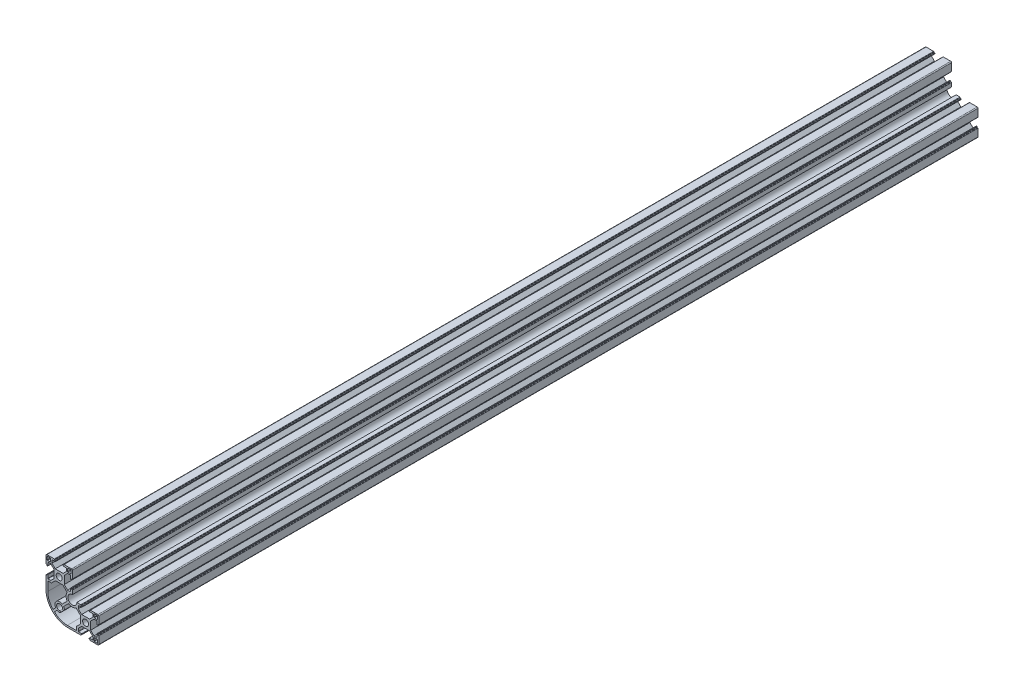
from build123d import *

# Parameters (mm, degrees)
SKETCH_1_R      = 3.4
EXTRUDE_1_DEPTH = 1000


with BuildPart() as part:
    # Эскиз1 → Бобышка-Вытянуть1 (new body)
    with BuildSketch(Plane.XY):
        with BuildLine():
            Line((-15, 38.25), (-15, 44))
            ThreePointArc((-15, 44), (-14.707106781, 44.707106781), (-14, 45))
            Line((-14, 45), (-8.25, 45))
            Line((-8.25, 45), (-5.5, 45))
            ThreePointArc((-5.5, 45), (-5.287867966, 44.912132034), (-5.2, 44.7))
            Line((-5.2, 44.7), (-5.2, 44.3))
            ThreePointArc((-5.2, 44.3), (-5.112132034, 44.087867966), (-4.9, 44))
            Line((-4.9, 44), (-4.4, 44))
            ThreePointArc((-4.4, 44), (-4.187867966, 43.912132034), (-4.1, 43.7))
            Line((-4.1, 43.7), (-4.1, 43.3))
            ThreePointArc((-4.1, 43.3), (-4.187867966, 43.087867966), (-4.4, 43))
            Line((-4.4, 43), (-7.95, 43))
            ThreePointArc((-7.95, 43), (-8.162132034, 42.912132034), (-8.25, 42.7))
            Line((-8.25, 42.7), (-8.25, 39.55))
            Line((-8.25, 39.55), (-4.5, 35.8))
            Line((-4.5, 35.8), (4.5, 35.8))
            Line((4.5, 35.8), (8.25, 39.55))
            Line((8.25, 39.55), (8.25, 42.7))
            ThreePointArc((8.25, 42.7), (8.162132034, 42.912132034), (7.95, 43))
            Line((7.95, 43), (4.4, 43))
            ThreePointArc((4.4, 43), (4.187867966, 43.087867966), (4.1, 43.3))
            Line((4.1, 43.3), (4.1, 43.7))
            ThreePointArc((4.1, 43.7), (4.187867966, 43.912132034), (4.4, 44))
            Line((4.4, 44), (4.9, 44))
            ThreePointArc((4.9, 44), (5.112132034, 44.087867966), (5.2, 44.3))
            Line((5.2, 44.3), (5.2, 44.7))
            ThreePointArc((5.2, 44.7), (5.287867966, 44.912132034), (5.5, 45))
            Line((5.5, 45), (8.25, 45))
            Line((8.25, 45), (14, 45))
            ThreePointArc((14, 45), (14.707106781, 44.707106781), (15, 44))
            Line((15, 44), (15, 38.25))
            Line((15, 38.25), (15, 35.5))
            ThreePointArc((15, 35.5), (14.912132034, 35.287867966), (14.7, 35.2))
            Line((14.7, 35.2), (14.3, 35.2))
            ThreePointArc((14.3, 35.2), (14.087867966, 35.112132034), (14, 34.9))
            Line((14, 34.9), (14, 34.4))
            ThreePointArc((14, 34.4), (13.912132034, 34.187867966), (13.7, 34.1))
            Line((13.7, 34.1), (13.3, 34.1))
            ThreePointArc((13.3, 34.1), (13.087867966, 34.187867966), (13, 34.4))
            Line((13, 34.4), (13, 37.95))
            ThreePointArc((13, 37.95), (12.912132034, 38.162132034), (12.7, 38.25))
            Line((12.7, 38.25), (9.55, 38.25))
            Line((9.55, 38.25), (5.8, 34.5))
            Line((5.8, 34.5), (5.8, 25.5))
            Line((5.8, 25.5), (9.55, 21.75))
            Line((9.55, 21.75), (12.7, 21.75))
            ThreePointArc((12.7, 21.75), (12.912132034, 21.837867966), (13, 22.05))
            Line((13, 22.05), (13, 25.6))
            ThreePointArc((13, 25.6), (13.087867966, 25.812132034), (13.3, 25.9))
            Line((13.3, 25.9), (13.7, 25.9))
            ThreePointArc((13.7, 25.9), (13.912132034, 25.812132034), (14, 25.6))
            Line((14, 25.6), (14, 25.1))
            ThreePointArc((14, 25.1), (14.087867966, 24.887867966), (14.3, 24.8))
            Line((14.3, 24.8), (14.7, 24.8))
            ThreePointArc((14.7, 24.8), (14.912132034, 24.712132034), (15, 24.5))
            Line((15, 24.5), (15, 21.75))
            Line((15, 21.75), (15, 20.1))
            ThreePointArc((15, 20.1), (11.393755416, 11.393755416), (20.1, 15))
            Line((20.1, 15), (21.75, 15))
            Line((21.75, 15), (24.5, 15))
            ThreePointArc((24.5, 15), (24.712132034, 14.912132034), (24.8, 14.7))
            Line((24.8, 14.7), (24.8, 14.3))
            ThreePointArc((24.8, 14.3), (24.887867966, 14.087867966), (25.1, 14))
            Line((25.1, 14), (25.6, 14))
            ThreePointArc((25.6, 14), (25.812132034, 13.912132034), (25.9, 13.7))
            Line((25.9, 13.7), (25.9, 13.3))
            ThreePointArc((25.9, 13.3), (25.812132034, 13.087867966), (25.6, 13))
            Line((25.6, 13), (22.05, 13))
            ThreePointArc((22.05, 13), (21.837867966, 12.912132034), (21.75, 12.7))
            Line((21.75, 12.7), (21.75, 9.55))
            Line((21.75, 9.55), (25.5, 5.8))
            Line((25.5, 5.8), (34.5, 5.8))
            Line((34.5, 5.8), (38.25, 9.55))
            Line((38.25, 9.55), (38.25, 12.7))
            ThreePointArc((38.25, 12.7), (38.162132034, 12.912132034), (37.95, 13))
            Line((37.95, 13), (34.4, 13))
            ThreePointArc((34.4, 13), (34.187867966, 13.087867966), (34.1, 13.3))
            Line((34.1, 13.3), (34.1, 13.7))
            ThreePointArc((34.1, 13.7), (34.187867966, 13.912132034), (34.4, 14))
            Line((34.4, 14), (34.9, 14))
            ThreePointArc((34.9, 14), (35.112132034, 14.087867966), (35.2, 14.3))
            Line((35.2, 14.3), (35.2, 14.7))
            ThreePointArc((35.2, 14.7), (35.287867966, 14.912132034), (35.5, 15))
            Line((35.5, 15), (38.25, 15))
            Line((38.25, 15), (44, 15))
            ThreePointArc((44, 15), (44.707106781, 14.707106781), (45, 14))
            Line((45, 14), (45, 8.25))
            Line((45, 8.25), (45, 5.5))
            ThreePointArc((45, 5.5), (44.912132034, 5.287867966), (44.7, 5.2))
            Line((44.7, 5.2), (44.3, 5.2))
            ThreePointArc((44.3, 5.2), (44.087867966, 5.112132034), (44, 4.9))
            Line((44, 4.9), (44, 4.4))
            ThreePointArc((44, 4.4), (43.912132034, 4.187867966), (43.7, 4.1))
            Line((43.7, 4.1), (43.3, 4.1))
            ThreePointArc((43.3, 4.1), (43.087867966, 4.187867966), (43, 4.4))
            Line((43, 4.4), (43, 7.95))
            ThreePointArc((43, 7.95), (42.912132034, 8.162132034), (42.7, 8.25))
            Line((42.7, 8.25), (39.55, 8.25))
            Line((39.55, 8.25), (35.8, 4.5))
            Line((35.8, 4.5), (35.8, -4.5))
            Line((35.8, -4.5), (39.55, -8.25))
            Line((39.55, -8.25), (42.7, -8.25))
            ThreePointArc((42.7, -8.25), (42.912132034, -8.162132034), (43, -7.95))
            Line((43, -7.95), (43, -4.4))
            ThreePointArc((43, -4.4), (43.087867966, -4.187867966), (43.3, -4.1))
            Line((43.3, -4.1), (43.7, -4.1))
            ThreePointArc((43.7, -4.1), (43.912132034, -4.187867966), (44, -4.4))
            Line((44, -4.4), (44, -4.9))
            ThreePointArc((44, -4.9), (44.087867966, -5.112132034), (44.3, -5.2))
            Line((44.3, -5.2), (44.7, -5.2))
            ThreePointArc((44.7, -5.2), (44.912132034, -5.287867966), (45, -5.5))
            Line((45, -5.5), (45, -8.25))
            Line((45, -8.25), (45, -14))
            ThreePointArc((45, -14), (44.707106781, -14.707106781), (44, -15))
            Line((44, -15), (38.25, -15))
            Line((38.25, -15), (35.5, -15))
            ThreePointArc((35.5, -15), (35.287867966, -14.912132034), (35.2, -14.7))
            Line((35.2, -14.7), (35.2, -14.3))
            ThreePointArc((35.2, -14.3), (35.112132034, -14.087867966), (34.9, -14))
            Line((34.9, -14), (34.4, -14))
            ThreePointArc((34.4, -14), (34.187867966, -13.912132034), (34.1, -13.7))
            Line((34.1, -13.7), (34.1, -13.3))
            ThreePointArc((34.1, -13.3), (34.187867966, -13.087867966), (34.4, -13))
            Line((34.4, -13), (37.95, -13))
            ThreePointArc((37.95, -13), (38.162132034, -12.912132034), (38.25, -12.7))
            Line((38.25, -12.7), (38.25, -9.55))
            Line((38.25, -9.55), (34.5, -5.8))
            Line((34.5, -5.8), (25.5, -5.8))
            Line((25.5, -5.8), (21.75, -9.55))
            Line((21.75, -9.55), (21.75, -12.7))
            ThreePointArc((21.75, -12.7), (21.837867966, -12.912132034), (22.05, -13))
            Line((22.05, -13), (25.6, -13))
            ThreePointArc((25.6, -13), (25.812132034, -13.087867966), (25.9, -13.3))
            Line((25.9, -13.3), (25.9, -13.7))
            ThreePointArc((25.9, -13.7), (25.812132034, -13.912132034), (25.6, -14))
            Line((25.6, -14), (25.1, -14))
            ThreePointArc((25.1, -14), (24.887867966, -14.087867966), (24.8, -14.3))
            Line((24.8, -14.3), (24.8, -14.7))
            ThreePointArc((24.8, -14.7), (24.712132034, -14.912132034), (24.5, -15))
            Line((24.5, -15), (21.75, -15))
            Line((21.75, -15), (10, -15))
            ThreePointArc((10, -15), (-7.67766953, -7.67766953), (-15, 10))
            Line((-15, 10), (-15, 21.75))
            Line((-15, 21.75), (-15, 24.5))
            ThreePointArc((-15, 24.5), (-14.912132034, 24.712132034), (-14.7, 24.8))
            Line((-14.7, 24.8), (-14.3, 24.8))
            ThreePointArc((-14.3, 24.8), (-14.087867966, 24.887867966), (-14, 25.1))
            Line((-14, 25.1), (-14, 25.6))
            ThreePointArc((-14, 25.6), (-13.912132034, 25.812132034), (-13.7, 25.9))
            Line((-13.7, 25.9), (-13.3, 25.9))
            ThreePointArc((-13.3, 25.9), (-13.087867966, 25.812132034), (-13, 25.6))
            Line((-13, 25.6), (-13, 22.05))
            ThreePointArc((-13, 22.05), (-12.912132034, 21.837867966), (-12.7, 21.75))
            Line((-12.7, 21.75), (-9.55, 21.75))
            Line((-9.55, 21.75), (-5.8, 25.5))
            Line((-5.8, 25.5), (-5.8, 34.5))
            Line((-5.8, 34.5), (-9.55, 38.25))
            Line((-9.55, 38.25), (-12.7, 38.25))
            ThreePointArc((-12.7, 38.25), (-12.912132034, 38.162132034), (-13, 37.95))
            Line((-13, 37.95), (-13, 34.4))
            ThreePointArc((-13, 34.4), (-13.087867966, 34.187867966), (-13.3, 34.1))
            Line((-13.3, 34.1), (-13.7, 34.1))
            ThreePointArc((-13.7, 34.1), (-13.912132034, 34.187867966), (-14, 34.4))
            Line((-14, 34.4), (-14, 34.9))
            ThreePointArc((-14, 34.9), (-14.087867966, 35.112132034), (-14.3, 35.2))
            Line((-14.3, 35.2), (-14.7, 35.2))
            ThreePointArc((-14.7, 35.2), (-14.912132034, 35.287867966), (-15, 35.5))
            Line((-15, 35.5), (-15, 38.25))
        make_face()
        with Locations((0, 30)):
            Circle(SKETCH_1_R, mode=Mode.SUBTRACT)
        with Locations((30, 0)):
            Circle(SKETCH_1_R, mode=Mode.SUBTRACT)
        with BuildLine():
            Line((-13.2, 43.7), (-10.2, 43.7))
            ThreePointArc((-10.2, 43.7), (-9.846446609, 43.553553391), (-9.7, 43.2))
            Line((-9.7, 43.2), (-9.7, 40.2))
            ThreePointArc((-9.7, 40.2), (-9.846446609, 39.846446609), (-10.2, 39.7))
            Line((-10.2, 39.7), (-13.2, 39.7))
            ThreePointArc((-13.2, 39.7), (-13.553553391, 39.846446609), (-13.7, 40.2))
            Line((-13.7, 40.2), (-13.7, 43.2))
            ThreePointArc((-13.7, 43.2), (-13.553553391, 43.553553391), (-13.2, 43.7))
        make_face(mode=Mode.SUBTRACT)
        with BuildLine():
            Line((13.2, 43.7), (10.2, 43.7))
            ThreePointArc((10.2, 43.7), (9.846446609, 43.553553391), (9.7, 43.2))
            Line((9.7, 43.2), (9.7, 40.2))
            ThreePointArc((9.7, 40.2), (9.846446609, 39.846446609), (10.2, 39.7))
            Line((10.2, 39.7), (13.2, 39.7))
            ThreePointArc((13.2, 39.7), (13.553553391, 39.846446609), (13.7, 40.2))
            Line((13.7, 40.2), (13.7, 43.2))
            ThreePointArc((13.7, 43.2), (13.553553391, 43.553553391), (13.2, 43.7))
        make_face(mode=Mode.SUBTRACT)
        with BuildLine():
            Line((43.7, 13.2), (43.7, 10.2))
            ThreePointArc((43.7, 10.2), (43.553553391, 9.846446609), (43.2, 9.7))
            Line((43.2, 9.7), (40.2, 9.7))
            ThreePointArc((40.2, 9.7), (39.846446609, 9.846446609), (39.7, 10.2))
            Line((39.7, 10.2), (39.7, 13.2))
            ThreePointArc((39.7, 13.2), (39.846446609, 13.553553391), (40.2, 13.7))
            Line((40.2, 13.7), (43.2, 13.7))
            ThreePointArc((43.2, 13.7), (43.553553391, 13.553553391), (43.7, 13.2))
        make_face(mode=Mode.SUBTRACT)
        with BuildLine():
            Line((39.7, -13.2), (39.7, -10.2))
            ThreePointArc((39.7, -10.2), (39.846446609, -9.846446609), (40.2, -9.7))
            Line((40.2, -9.7), (43.2, -9.7))
            ThreePointArc((43.2, -9.7), (43.553553391, -9.846446609), (43.7, -10.2))
            Line((43.7, -10.2), (43.7, -13.2))
            ThreePointArc((43.7, -13.2), (43.553553391, -13.553553391), (43.2, -13.7))
            Line((43.2, -13.7), (40.2, -13.7))
            ThreePointArc((40.2, -13.7), (39.846446609, -13.553553391), (39.7, -13.2))
        make_face(mode=Mode.SUBTRACT)
        with BuildLine():
            Line((-13, 19.75), (-13, 9.25))
            ThreePointArc((-13, 9.25), (-11.424735256, 1.33060934), (-6.9387608, -5.383125881))
            Line((-6.9387608, -5.383125881), (-4.016132588, -2.460497669))
            ThreePointArc((-4.016132588, -2.460497669), (-3.318376618, 4.318376618), (3.460497669, 5.016132588))
            Line((3.460497669, 5.016132588), (9.190781145, 10.746416064))
            ThreePointArc((9.190781145, 10.746416064), (7.800006577, 15.009731651), (9.202300803, 19.269272072))
            Line((9.202300803, 19.269272072), (4.271572875, 24.2))
            Line((4.271572875, 24.2), (-4.271572875, 24.2))
            Line((-4.271572875, 24.2), (-8.721572875, 19.75))
            Line((-8.721572875, 19.75), (-13, 19.75))
        make_face(mode=Mode.SUBTRACT)
        with BuildLine():
            Line((19.75, -13), (9.25, -13))
            ThreePointArc((9.25, -13), (1.33060934, -11.424735256), (-5.383125881, -6.9387608))
            Line((-5.383125881, -6.9387608), (-2.460497669, -4.016132588))
            ThreePointArc((-2.460497669, -4.016132588), (-1.04481132, -4.674317152), (0.5, -4.9))
            ThreePointArc((0.5, -4.9), (1.5, -3.9), (0.5, -2.9))
            ThreePointArc((0.5, -2.9), (-1.904163056, 2.904163056), (3.9, 0.5))
            ThreePointArc((3.9, 0.5), (4.9, -0.5), (5.9, 0.5))
            ThreePointArc((5.9, 0.5), (5.674317152, 2.04481132), (5.016132588, 3.460497669))
            Line((5.016132588, 3.460497669), (10.746416064, 9.190781145))
            ThreePointArc((10.746416064, 9.190781145), (15.009731651, 7.800006577), (19.269272072, 9.202300803))
            Line((19.269272072, 9.202300803), (24.2, 4.271572875))
            Line((24.2, 4.271572875), (24.2, -4.271572875))
            Line((24.2, -4.271572875), (19.75, -8.721572875))
            Line((19.75, -8.721572875), (19.75, -13))
        make_face(mode=Mode.SUBTRACT)
    extrude(amount=EXTRUDE_1_DEPTH)


solid = part.part
